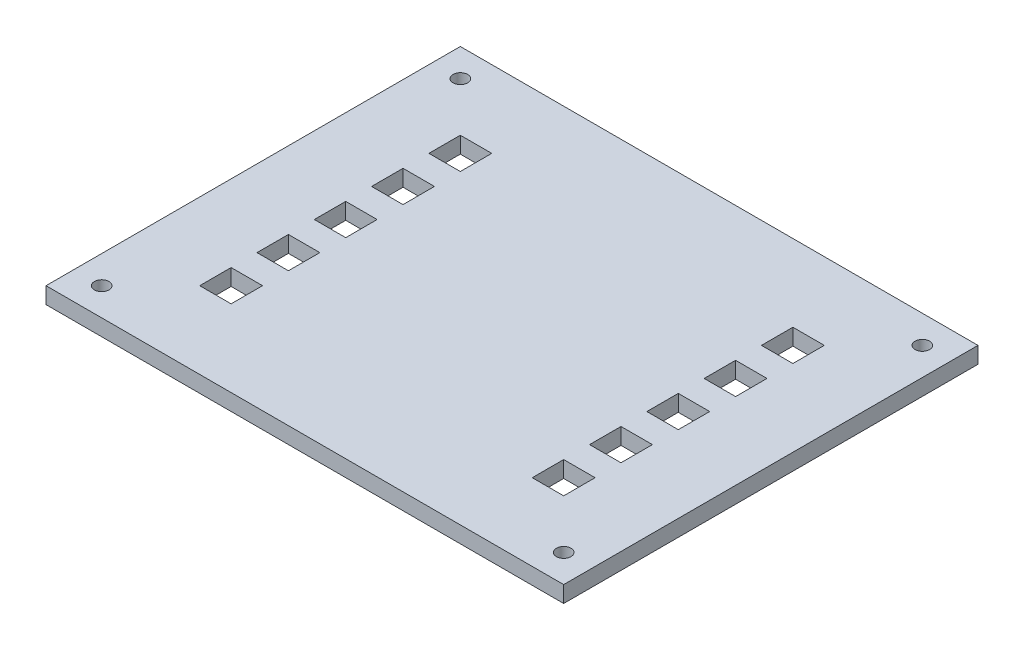
from build123d import *

# Parameters (mm, degrees)
SKETCH1_W           = 100.17
SKETCH1_H           = 80.17
BOSS_EXTRUDE1_DEPTH = 3.175
SKETCH2_W           = 6.08
SKETCH2_H           = 6.08
CUT_EXTRUDE2_DEPTH  = 4.175
LPATTERN1_COUNT     = 5
LPATTERN1_PITCH     = 11.0875
SKETCH4_R           = 1.415
CUT_EXTRUDE3_DEPTH  = 6.35


with BuildPart() as part:
    # Sketch1 → Boss-Extrude1 (new body)
    with BuildSketch(Plane(origin=(0, 0, 0), x_dir=(1, 0, 0), z_dir=(0, 1, 0))):
        Rectangle(SKETCH1_W, SKETCH1_H)
    extrude(amount=BOSS_EXTRUDE1_DEPTH)

    # Sketch2 → Cut-Extrude2 (cut, through all)
    with BuildSketch(Plane(origin=(0, 3.175, 0), x_dir=(1, 0, 0), z_dir=(0, 1, 0))):
        with Locations((-32.175, 22.175)):
            Rectangle(SKETCH2_W, SKETCH2_H)
        with Locations((32.175, 22.175)):
            Rectangle(SKETCH2_W, SKETCH2_H)
    cut_extrude2 = extrude(amount=-CUT_EXTRUDE2_DEPTH, mode=Mode.SUBTRACT)

    # LPattern1: Cut-Extrude2 ×5
    with Locations(*[(0, 0, i * LPATTERN1_PITCH) for i in range(1, LPATTERN1_COUNT)]):
        add(cut_extrude2, mode=Mode.SUBTRACT)

    # Sketch4 → Cut-Extrude3 (cut)
    with BuildSketch(Plane(origin=(0, 3.175, 0), x_dir=(1, 0, 0), z_dir=(0, 1, 0))):
        with Locations((-44.696699141, 34.696699141)):
            Circle(SKETCH4_R)
        with Locations((44.696699141, 34.696699141)):
            Circle(SKETCH4_R)
        with Locations((44.696699141, -34.696699141)):
            Circle(SKETCH4_R)
        with Locations((-44.696699141, -34.696699141)):
            Circle(SKETCH4_R)
    extrude(amount=-CUT_EXTRUDE3_DEPTH, mode=Mode.SUBTRACT)


solid = part.part
